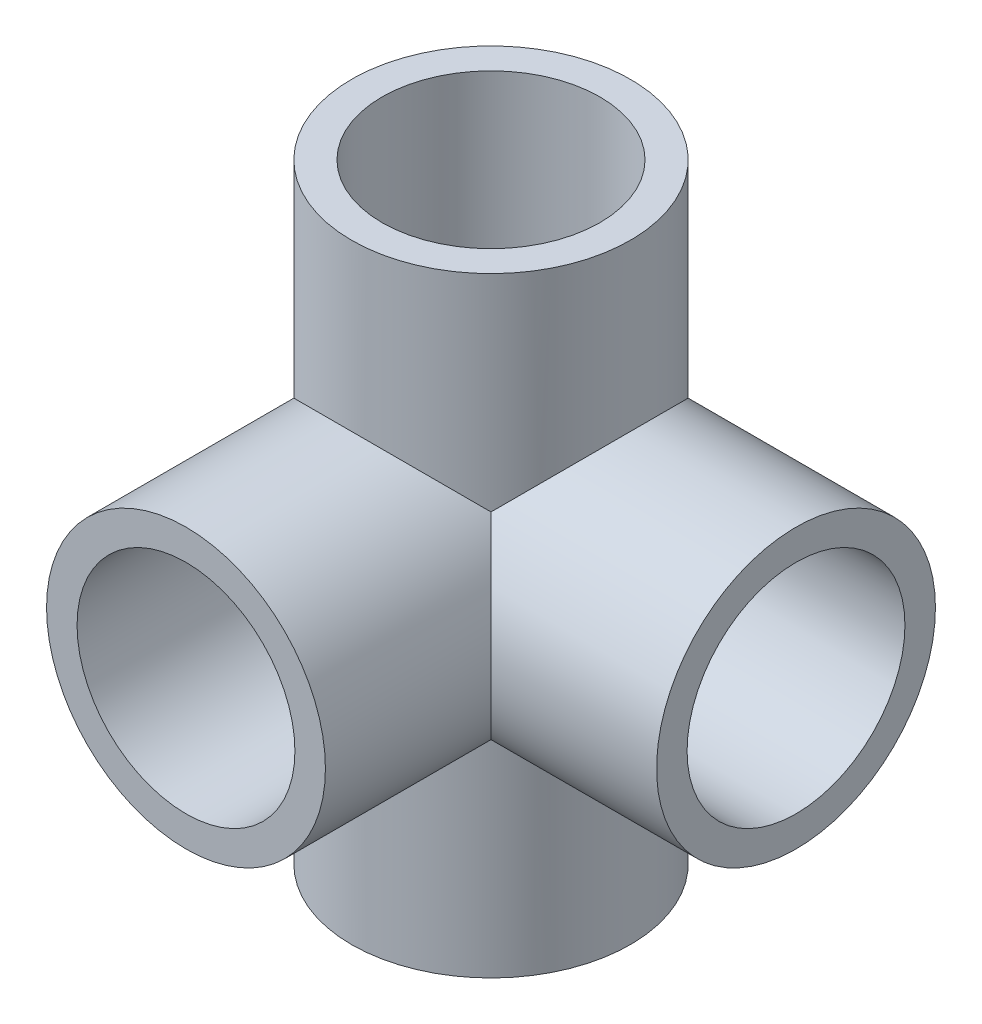
from build123d import *

# Parameters (mm, degrees)
SKETCH_1_R      = 16
SKETCH_1_R_2    = 12.5
EXTRUDE_1_DEPTH = 35
SKETCH_2_R      = 16
SKETCH_2_R_2    = 12.5
EXTRUDE_2_DEPTH = 35
SKETCH_4_R      = 16
SKETCH_4_R_2    = 12.5
EXTRUDE_3_DEPTH = 35
REVOLVE_1_ANGLE = 90
SKETCH_5_R      = 16
SKETCH_5_R_2    = 12.5
EXTRUDE_4_DEPTH = 35


with BuildPart() as part:
    # 草图1 → 凸台-拉伸1 (new body)
    with BuildSketch(Plane.XY):
        Circle(SKETCH_1_R)
        Circle(SKETCH_1_R_2, mode=Mode.SUBTRACT)
    extrude(amount=EXTRUDE_1_DEPTH)

    # 草图2 → 凸台-拉伸2 (add)
    with BuildSketch(Plane(origin=(0, 0, 0), x_dir=(0, 0, -1), z_dir=(1, 0, 0))):
        with Locations(Location((0, 0, 0), (0, 0, 90))):
            Circle(SKETCH_2_R)
        with Locations(Location((0, 0, 0), (0, 0, 270))):
            Circle(SKETCH_2_R_2, mode=Mode.SUBTRACT)
    extrude(amount=EXTRUDE_2_DEPTH)

    # 草图4 → 凸台-拉伸3 (add)
    with BuildSketch(Plane(origin=(0, 0, 0), x_dir=(1, 0, 0), z_dir=(0, 1, 0))):
        with Locations(Location((0, 0, 0), (0, 0, 90))):
            Circle(SKETCH_4_R)
        with Locations(Location((0, 0, 0), (0, 0, 90))):
            Circle(SKETCH_4_R_2, mode=Mode.SUBTRACT)
    extrude(amount=EXTRUDE_3_DEPTH)

    # 草图3 → 旋转1 (revolve)
    with BuildSketch(Plane.XY):
        with BuildLine():
            Line((0, 16), (0, -16))
            ThreePointArc((0, -16), (-16, 0), (0, 16))
        make_face()
    revolve(axis=Axis((0, 16, 0), (0, -1, 0)), revolution_arc=REVOLVE_1_ANGLE)

    # 草图5 → 凸台-拉伸4 (add)
    with BuildSketch(Plane(origin=(0, 0, 0), x_dir=(1, 0, 0), z_dir=(0, 1, 0))):
        with Locations(Location((0, 0, 0), (0, 0, 270))):
            Circle(SKETCH_5_R)
        with Locations(Location((0, 0, 0), (0, 0, 90))):
            Circle(SKETCH_5_R_2, mode=Mode.SUBTRACT)
    extrude(amount=-EXTRUDE_4_DEPTH)


solid = part.part
